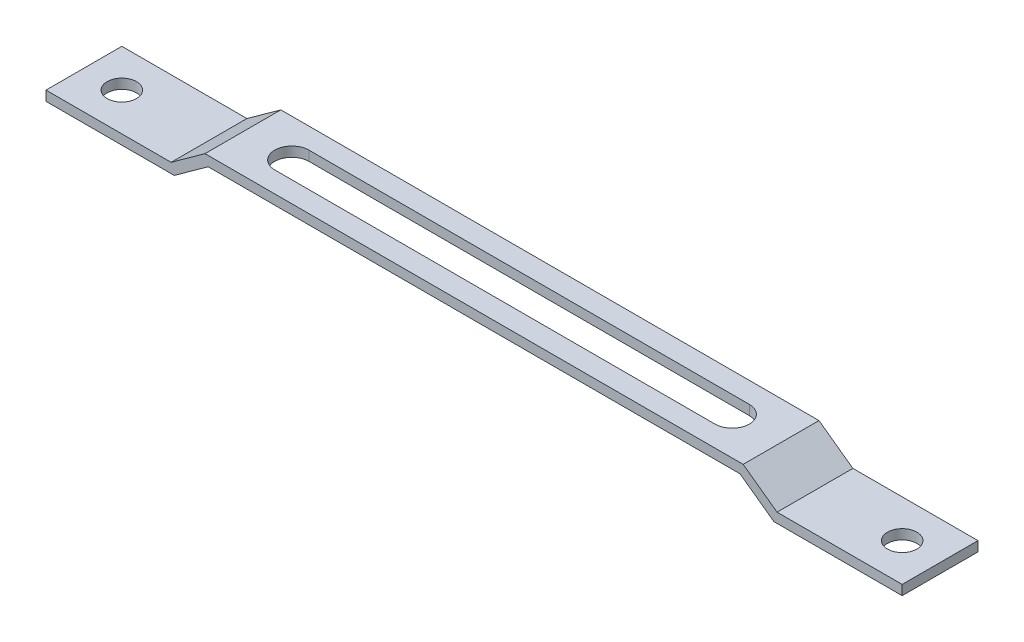
from build123d import *

# Parameters (mm, degrees)
EXTRUDE_1_DEPTH     = 15.5
SKETCH_2_R          = 3
CUT_EXTRUDE_1_DEPTH = 10


with BuildPart() as part:
    # Эскиз1 → Вытянуть-Тонкостенный1 (new body)
    with BuildSketch(Plane.XY):
        Polygon((87.5, 0), (61.92820323, 0), (55, 5), (-55, 5), (-61.92820323, 0), (-87.5, 0), (-87.5, -2), (-61.281883024, -2), (-54.353679794, 3), (54.353679794, 3), (61.281883024, -2), (87.5, -2), align=None)
    extrude(amount=EXTRUDE_1_DEPTH)

    # Эскиз2 → Вырез-Вытянуть1 (cut)
    with BuildSketch(Plane(origin=(0, 5, 0), x_dir=(1, 0, 0), z_dir=(0, 1, 0))):
        with Locations((-79.75, -7.75)):
            Circle(SKETCH_2_R)
        with Locations((79.75, -7.75)):
            Circle(SKETCH_2_R)
        with BuildLine():
            Line((-45, -4.25), (45, -4.25))
            ThreePointArc((45, -4.25), (48.5, -7.75), (45, -11.25))
            Line((45, -11.25), (-45, -11.25))
            ThreePointArc((-45, -11.25), (-48.5, -7.75), (-45, -4.25))
        make_face()
    extrude(amount=-CUT_EXTRUDE_1_DEPTH, mode=Mode.SUBTRACT)


solid = part.part
